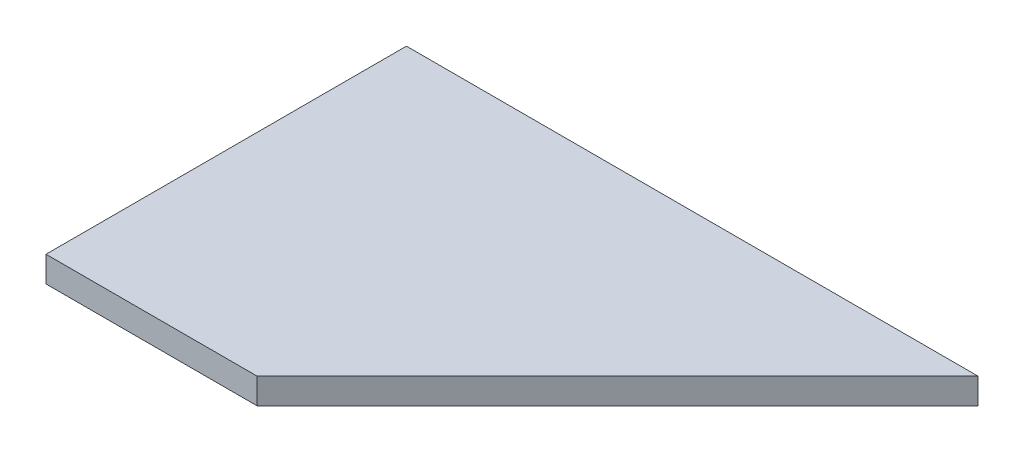
from build123d import *

# Parameters (mm, degrees)
BOSS_EXTRUDE1_DEPTH = 3


with BuildPart() as part:
    # Sketch1 → Boss-Extrude1 (new body)
    with BuildSketch(Plane(origin=(0, 0, 0), x_dir=(1, 0, 0), z_dir=(0, 1, 0))):
        Polygon((33.3, 21), (-8.7, -21), (-33.3, -21), (-33.3, 21), align=None)
    extrude(amount=BOSS_EXTRUDE1_DEPTH)


solid = part.part
